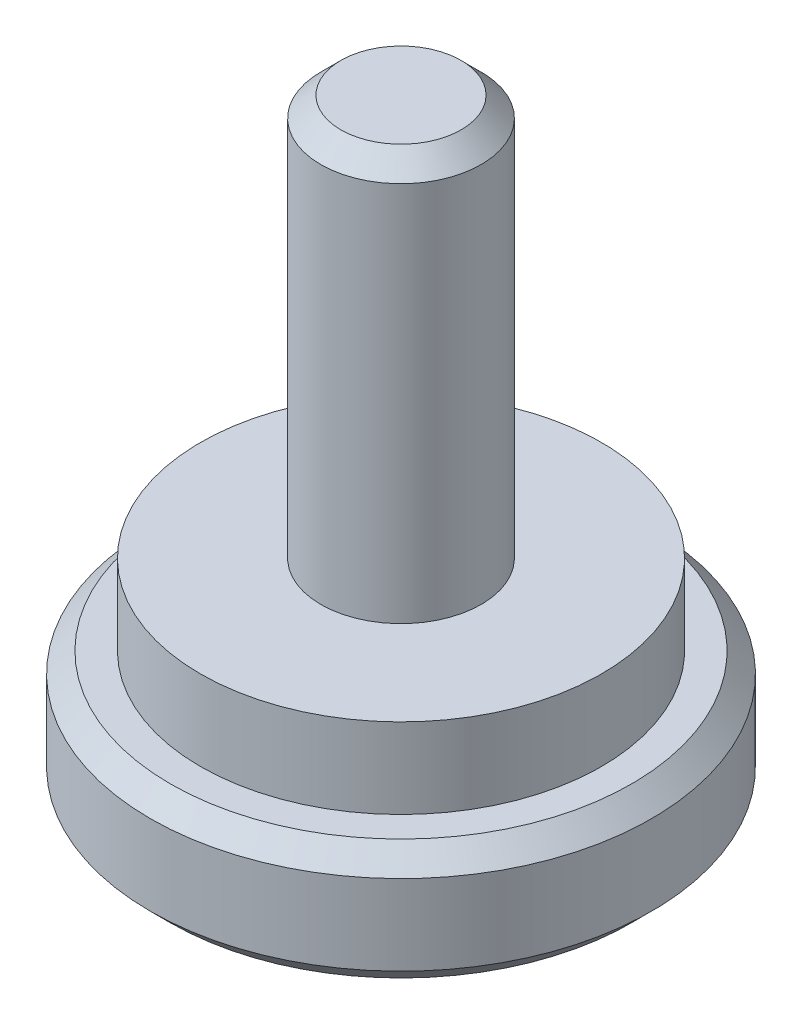
from build123d import *

# Parameters (mm, degrees)
ESQUISSE1_R      = 6.25
EXTRUSION1_DEPTH = 3
ESQUISSE2_R      = 5
EXTRUSION2_DEPTH = 2
ESQUISSE3_R      = 2
EXTRUSION3_DEPTH = 10
CHANFREIN1_SIZE  = 0.5
CHANFREIN2_SIZE  = 0.5
EXTRUSION4_DEPTH = 4


with BuildPart() as part:
    # Esquisse1 → Extrusion1 (new body)
    with BuildSketch(Plane(origin=(0, 0, 0), x_dir=(1, 0, 0), z_dir=(0, 1, 0))):
        Circle(ESQUISSE1_R)
    extrude(amount=EXTRUSION1_DEPTH)

    # Esquisse2 → Extrusion2 (add)
    with BuildSketch(Plane(origin=(0, 3, 0), x_dir=(1, 0, 0), z_dir=(0, 1, 0))):
        Circle(ESQUISSE2_R)
    extrude(amount=EXTRUSION2_DEPTH)

    # Esquisse3 → Extrusion3 (add)
    with BuildSketch(Plane(origin=(0, 5, 0), x_dir=(1, 0, 0), z_dir=(0, 1, 0))):
        Circle(ESQUISSE3_R)
    extrude(amount=EXTRUSION3_DEPTH)

    # Chanfrein1
    chanfrein1_edges = [part.edges().sort_by_distance(p)[0] for p in [
        (-6.25, 0, 0),
        (-6.25, 3, 0),
    ]]
    chamfer(chanfrein1_edges, length=CHANFREIN1_SIZE)

    # Chanfrein2
    chanfrein2_edges = [part.edges().sort_by_distance(p)[0] for p in [
        (-2, 15, 0),
    ]]
    chamfer(chanfrein2_edges, length=CHANFREIN2_SIZE)

    # Esquisse4 → Extrusion4 (cut)
    with BuildSketch(Plane.XZ):
        Polygon((0, 2.309401077), (-2, 1.154700538), (-2, -1.154700538), (0, -2.309401077), (2, -1.154700538), (2, 1.154700538), align=None)
    extrude(amount=-EXTRUSION4_DEPTH, mode=Mode.SUBTRACT)


solid = part.part
